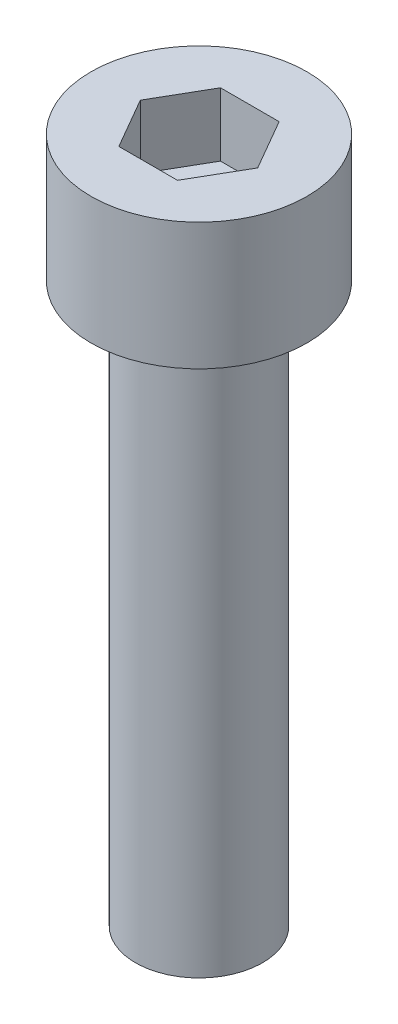
from build123d import *

# Parameters (mm, degrees)
SKETCH_1_R          = 4.25
EXTRUDE_1_DEPTH     = 5
CUT_EXTRUDE_1_DEPTH = 2.5
SKETCH_3_R          = 2.5
EXTRUDE_2_DEPTH     = 22


with BuildPart() as part:
    # 草图1 → 凸台-拉伸1 (new body)
    with BuildSketch(Plane(origin=(0, 0, 0), x_dir=(1, 0, 0), z_dir=(0, 1, 0))):
        Circle(SKETCH_1_R)
    extrude(amount=EXTRUDE_1_DEPTH)

    # 草图2 → 切除-拉伸1 (cut)
    with BuildSketch(Plane(origin=(0, 5, 0), x_dir=(1, 0, 0), z_dir=(0, 1, 0))):
        Polygon((2.309401077, 0), (1.154700538, 2), (-1.154700538, 2), (-2.309401077, 0), (-1.154700538, -2), (1.154700538, -2), align=None)
    extrude(amount=-CUT_EXTRUDE_1_DEPTH, mode=Mode.SUBTRACT)

    # 草图3 → 凸台-拉伸2 (add)
    with BuildSketch(Plane.XZ):
        Circle(SKETCH_3_R)
    extrude(amount=EXTRUDE_2_DEPTH)


solid = part.part
